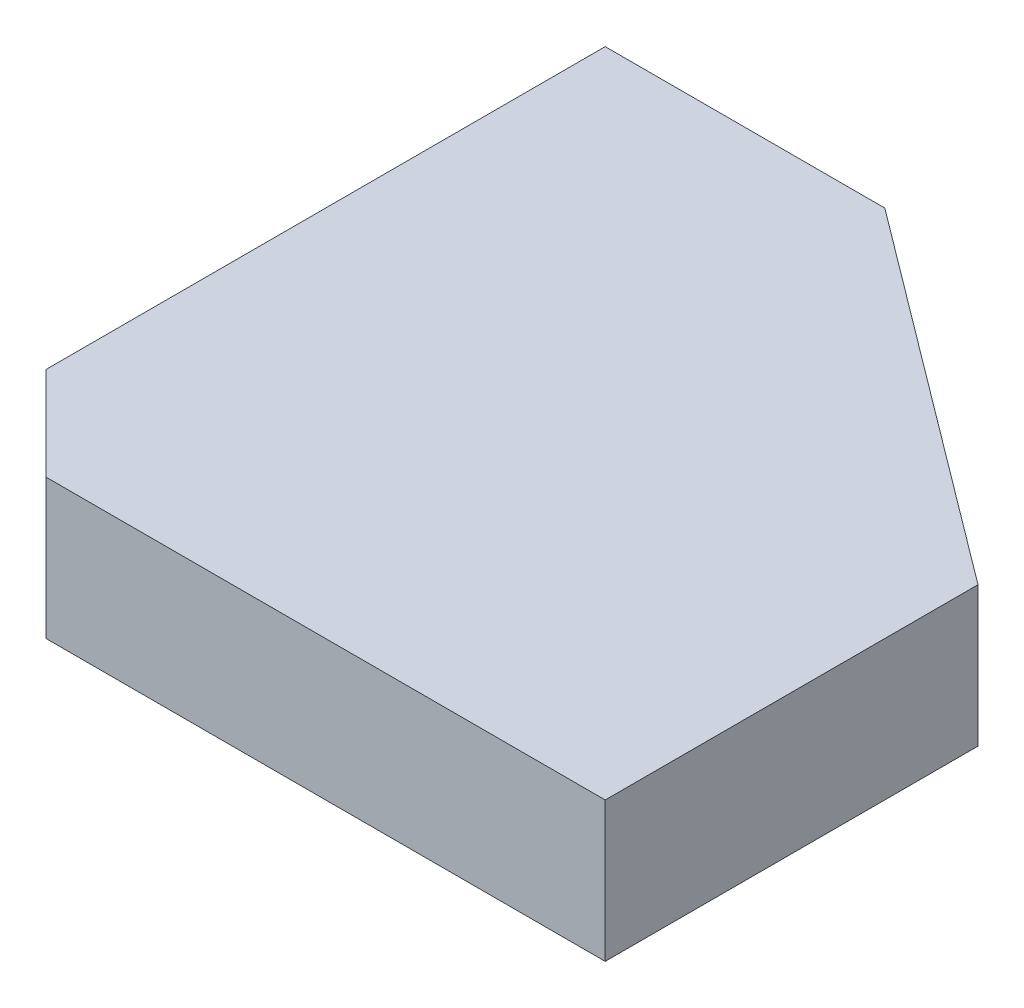
from build123d import *

# Parameters (mm, degrees)
BASE_EXTRUDE_DEPTH = 4.7625
CHAMFER1_SIZE      = 6.35


with BuildPart() as part:
    # Sketch1 → Base-Extrude (new body, symmetric)
    with BuildSketch(Plane(origin=(0, 0, 0), x_dir=(1, 0, 0), z_dir=(0, 1, 0))):
        Polygon((0, 0), (44.45, 0), (44.45, 25.4), (19.05, 44.45), (0, 44.45), align=None)
    extrude(amount=BASE_EXTRUDE_DEPTH, both=True)

    # Chamfer1
    chamfer1_edges = [part.edges().sort_by_distance(p)[0] for p in [
        (0, 0, 0),
    ]]
    chamfer(chamfer1_edges, length=CHAMFER1_SIZE)


solid = part.part
